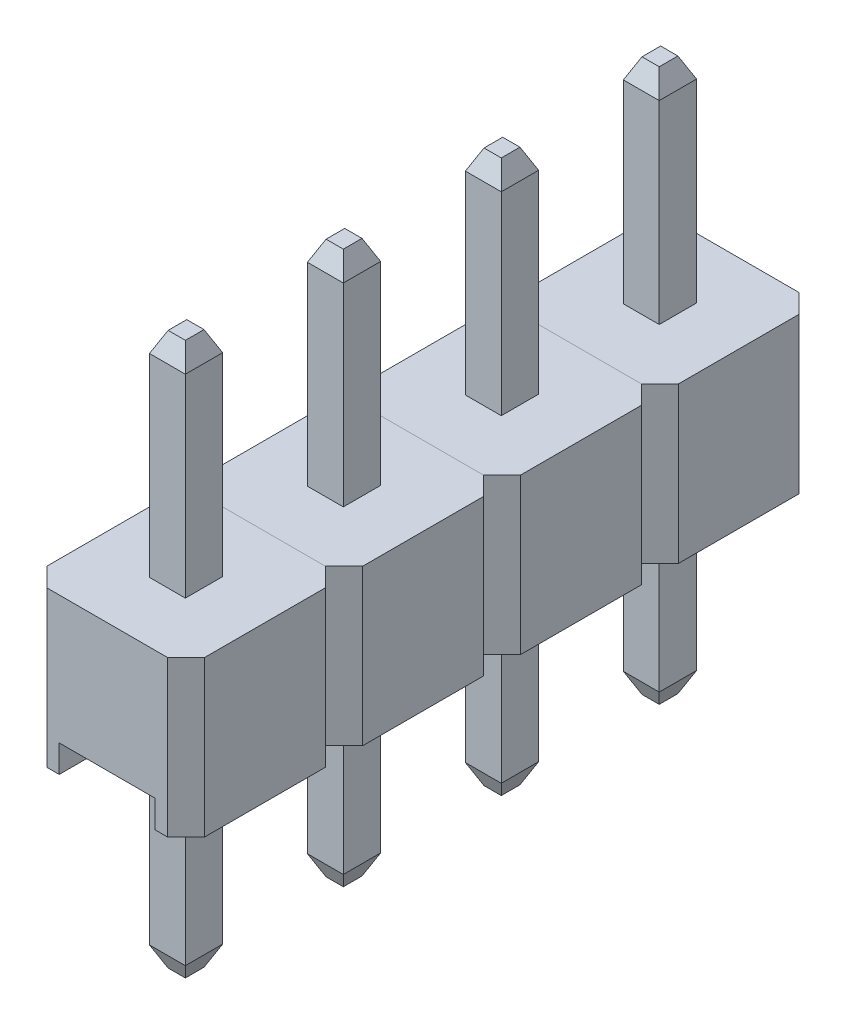
from build123d import *

# Parameters (mm, degrees)
CUERPO_PL_STICO_DEPTH = 2.5
CROQUIS2_W            = 1.54
CROQUIS2_H            = 2.54
RANURA_DEPTH          = 0.44
CROQUIS3_W            = 0.57750613
CROQUIS3_H            = 0.6
PIN_DEPTH             = 3.44
PIN_DEPTH_BACK        = 5.44
CHAFL_N1_SIZE         = 0.15
CHAFL_N1_SIZE2        = 0.321676038
CHAFL_N2_SIZE         = 0.15
CHAFL_N2_SIZE2        = 0.321676038
MATRIZ_COUNT          = 4
MATRIZ_PITCH          = 2.54


with BuildPart() as part:
    # Croquis1 → Cuerpo Plástico (new body)
    with BuildSketch(Plane(origin=(0, 0, 0), x_dir=(1, 0, 0), z_dir=(0, 1, 0))):
        Polygon((0.3, 0), (2.24, 0), (2.54, 0.3), (2.54, 2.24), (2.24, 2.54), (0.3, 2.54), (0, 2.24), (0, 0.3), align=None)
    extrude(amount=CUERPO_PL_STICO_DEPTH)

    # Croquis2 → Ranura (cut)
    with BuildSketch(Plane.XZ):
        with Locations((1.27, -1.27)):
            Rectangle(CROQUIS2_W, CROQUIS2_H)
    extrude(amount=-RANURA_DEPTH, mode=Mode.SUBTRACT)

    # Croquis3 → Pin (add, two sides)
    with BuildSketch(Plane(origin=(0, 2.5, 0), x_dir=(1, 0, 0), z_dir=(0, 1, 0))) as pin_sk:
        with Locations((1.27, 1.27)):
            Rectangle(CROQUIS3_W, CROQUIS3_H)
    extrude(amount=PIN_DEPTH)
    extrude(pin_sk.sketch, amount=-PIN_DEPTH_BACK)

    # Chaflán1
    chafl_n1_edges = [part.edges().sort_by_distance(p)[0] for p in [
        (0.981246935, 5.94, -1.27),
        (1.27, 5.94, -0.97),
        (1.558753065, 5.94, -1.27),
        (1.27, 5.94, -1.57),
    ]]
    chafl_n1_side = [part.faces().sort_by_distance(p)[0] for p in [
        (1.27, 5.94, -1.27),
    ]]
    chamfer(chafl_n1_edges, length=CHAFL_N1_SIZE, length2=CHAFL_N1_SIZE2, reference=chafl_n1_side[0])

    # Chaflán2
    chafl_n2_edges = [part.edges().sort_by_distance(p)[0] for p in [
        (0.981246935, -2.94, -1.27),
        (1.27, -2.94, -1.57),
        (1.558753065, -2.94, -1.27),
        (1.27, -2.94, -0.97),
    ]]
    chafl_n2_side = [part.faces().sort_by_distance(p)[0] for p in [
        (1.27, -2.94, -1.27),
    ]]
    chamfer(chafl_n2_edges, length=CHAFL_N2_SIZE, length2=CHAFL_N2_SIZE2, reference=chafl_n2_side[0])


with BuildPart() as matriz_1:
    # Matriz: pattern copy
    add(part.part.moved(Location(Vector(0, 0, 1) * (1 * MATRIZ_PITCH))))


with BuildPart() as matriz_2:
    # Matriz: pattern copy
    add(part.part.moved(Location(Vector(0, 0, 1) * (2 * MATRIZ_PITCH))))


with BuildPart() as matriz_3:
    # Matriz: pattern copy
    add(part.part.moved(Location(Vector(0, 0, 1) * (3 * MATRIZ_PITCH))))


solid = Compound([part.part, matriz_1.part, matriz_2.part, matriz_3.part])
